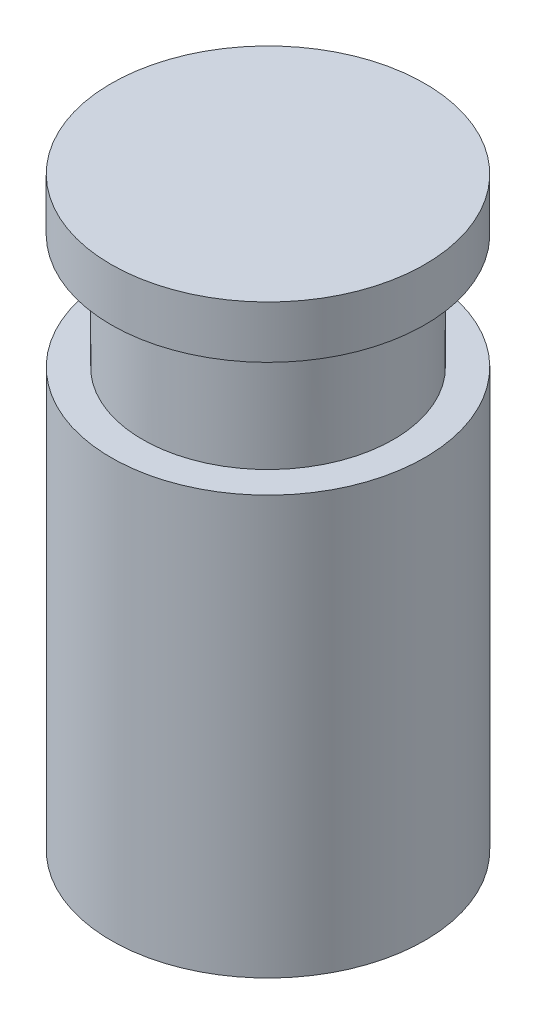
from build123d import *

# Parameters (mm, degrees)
SKETCH1_R           = 6
BOSS_EXTRUDE1_DEPTH = 8
SKETCH3_R           = 7.5
BOSS_EXTRUDE2_DEPTH = 20
SKETCH4_R           = 7.5
BOSS_EXTRUDE3_DEPTH = 2.5


with BuildPart() as part:
    # Sketch1 → Boss-Extrude1 (new body)
    with BuildSketch(Plane(origin=(0, 0, 0), x_dir=(1, 0, 0), z_dir=(0, 1, 0))):
        Circle(SKETCH1_R)
    extrude(amount=BOSS_EXTRUDE1_DEPTH)

    # Sketch3 → Boss-Extrude2 (add)
    with BuildSketch(Plane.XZ):
        Circle(SKETCH3_R)
    extrude(amount=BOSS_EXTRUDE2_DEPTH)

    # Sketch4 → Boss-Extrude3 (add)
    with BuildSketch(Plane(origin=(0, 8, 0), x_dir=(1, 0, 0), z_dir=(0, 1, 0))):
        Circle(SKETCH4_R)
    extrude(amount=-BOSS_EXTRUDE3_DEPTH)


solid = part.part
